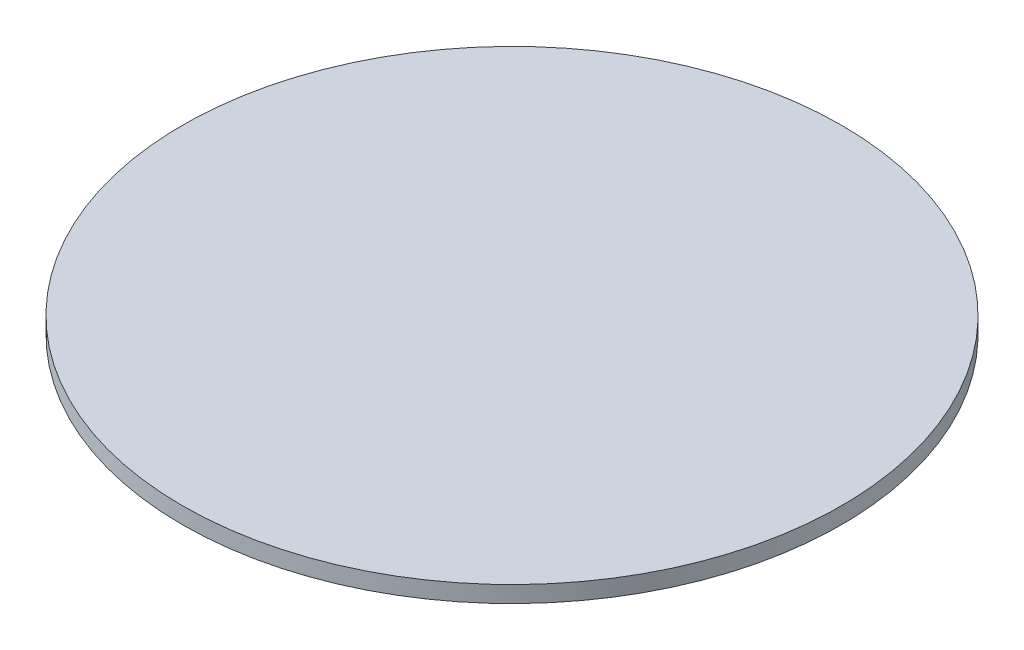
from build123d import *

# Parameters (mm, degrees)
SKETCH1_R      = 10
PFA_FILM_DEPTH = 0.5


with BuildPart() as part:
    # Sketch1 → PFA film (new body)
    with BuildSketch(Plane(origin=(0, 0, 0), x_dir=(1, 0, 0), z_dir=(0, 1, 0))):
        Circle(SKETCH1_R)
    extrude(amount=PFA_FILM_DEPTH)


solid = part.part
